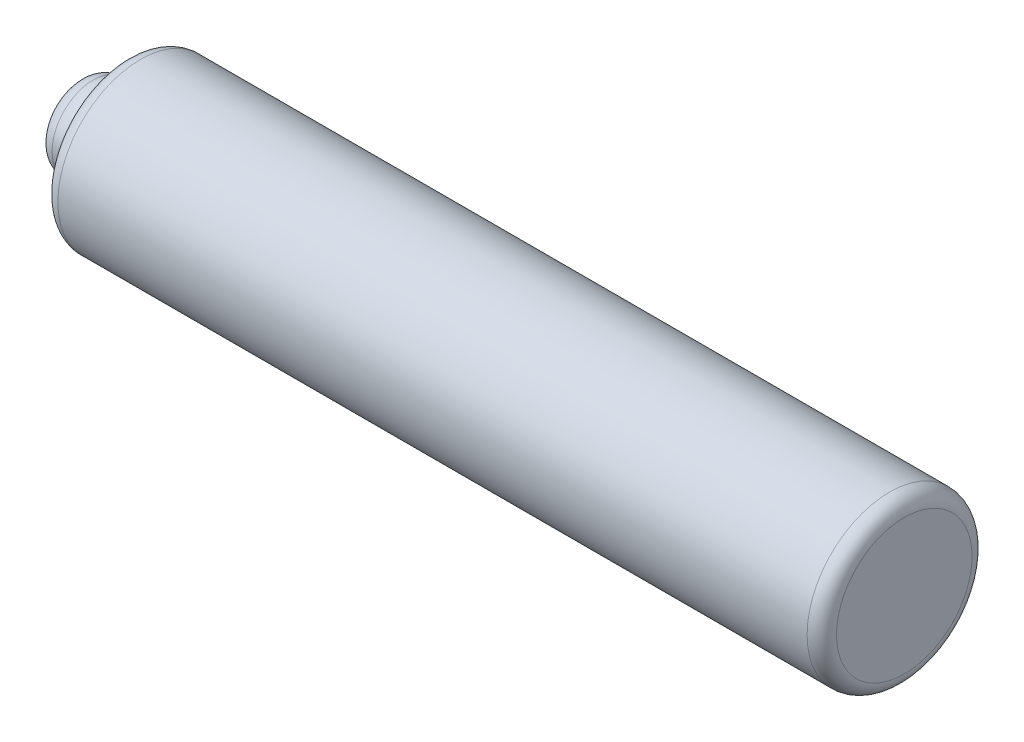
from build123d import *

# Parameters (mm, degrees)
FILLET2_R = 0.762


with BuildPart() as part:
    # Sketch1 → Revolve1 (revolve)
    with BuildSketch(Plane(origin=(0, 0, 0), x_dir=(1, 0, 0), z_dir=(0, 1, 0))):
        Polygon((-45.844442062, 21.494886281), (-5.451340986, 21.494886281), (-5.451340986, 17.215205983), (-45.844442062, 17.215205983), (-48.285381023, 17.215205983), (-48.285381023, 19.355046132), (-45.844442062, 19.355046132), align=None)
    revolve(axis=Axis((-45.844442062, 0, -17.215205983), (1, 0, 0)))

    # Fillet2
    fillet2_edges = [part.edges().sort_by_distance(p)[0] for p in [
        (-48.285381023, 0, -15.075365834),
        (-5.451340986, 0, -12.935525685),
        (-45.844442062, 0, -12.935525685),
    ]]
    fillet(fillet2_edges, radius=FILLET2_R)


solid = part.part
